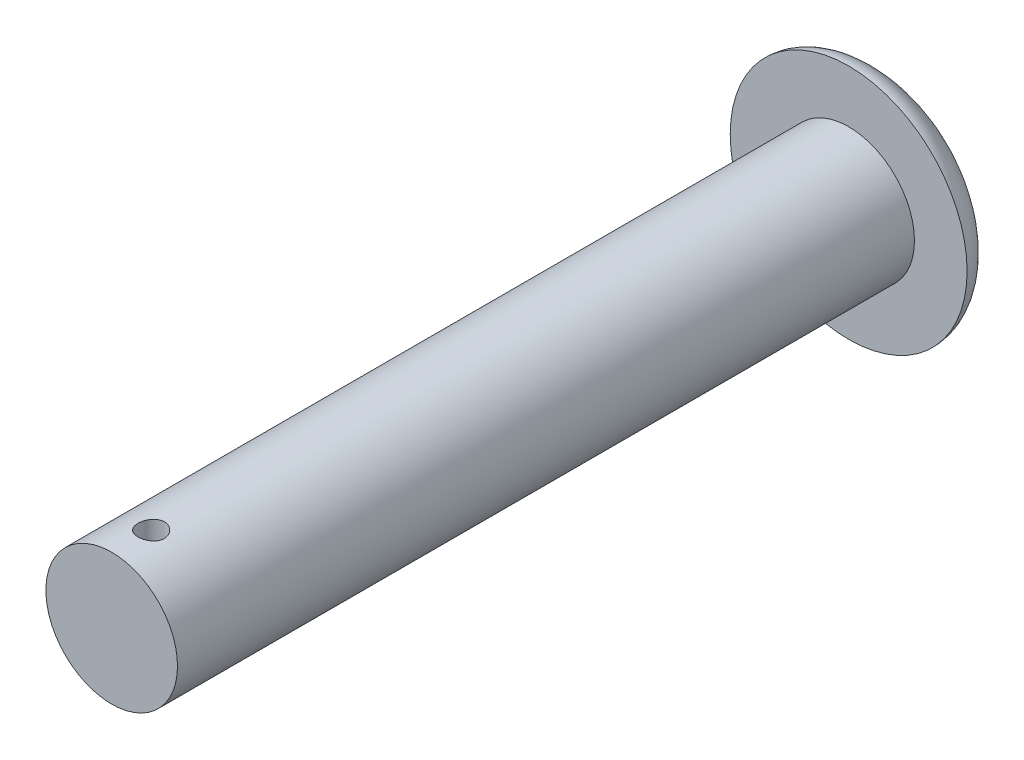
from build123d import *

# Parameters (mm, degrees)
SKETCH2_R               = 0.5
CUT_EXTRUDE1_DEPTH      = 5.5000001
CUT_EXTRUDE1_DEPTH_BACK = 5.5000001


with BuildPart() as part:
    # Sketch1 → Revolve1 (revolve)
    with BuildSketch(Plane(origin=(0, 0, 0), x_dir=(1, 0, 0), z_dir=(0, 1, 0))):
        with BuildLine():
            Line((0, 0), (0, 30))
            add(Edge.make_bspline(
                [(0, 30), (-4.5, 30), (-4.5, 28)],
                knots=[4.71238898, 4.71238898, 4.71238898, 6.283185307, 6.283185307, 6.283185307], degree=2, weights=[1, 0.707106781, 1]))
            Line((-4.5, 28), (-2.5, 28))
            Line((-2.5, 28), (-2.5, 0))
            Line((-2.5, 0), (0, 0))
        make_face()
    revolve(axis=Axis((0, 0, 0), (0, 0, -1)))

    # Sketch2 → Cut-Extrude1 (cut, two sides)
    with BuildSketch(Plane(origin=(0, 0, 0), x_dir=(1, 0, 0), z_dir=(0, 1, 0))) as cut_extrude1_sk:
        with Locations((0, 1.5)):
            Circle(SKETCH2_R)
    extrude(amount=CUT_EXTRUDE1_DEPTH, mode=Mode.SUBTRACT)
    extrude(cut_extrude1_sk.sketch, amount=-CUT_EXTRUDE1_DEPTH_BACK, mode=Mode.SUBTRACT)


solid = part.part
